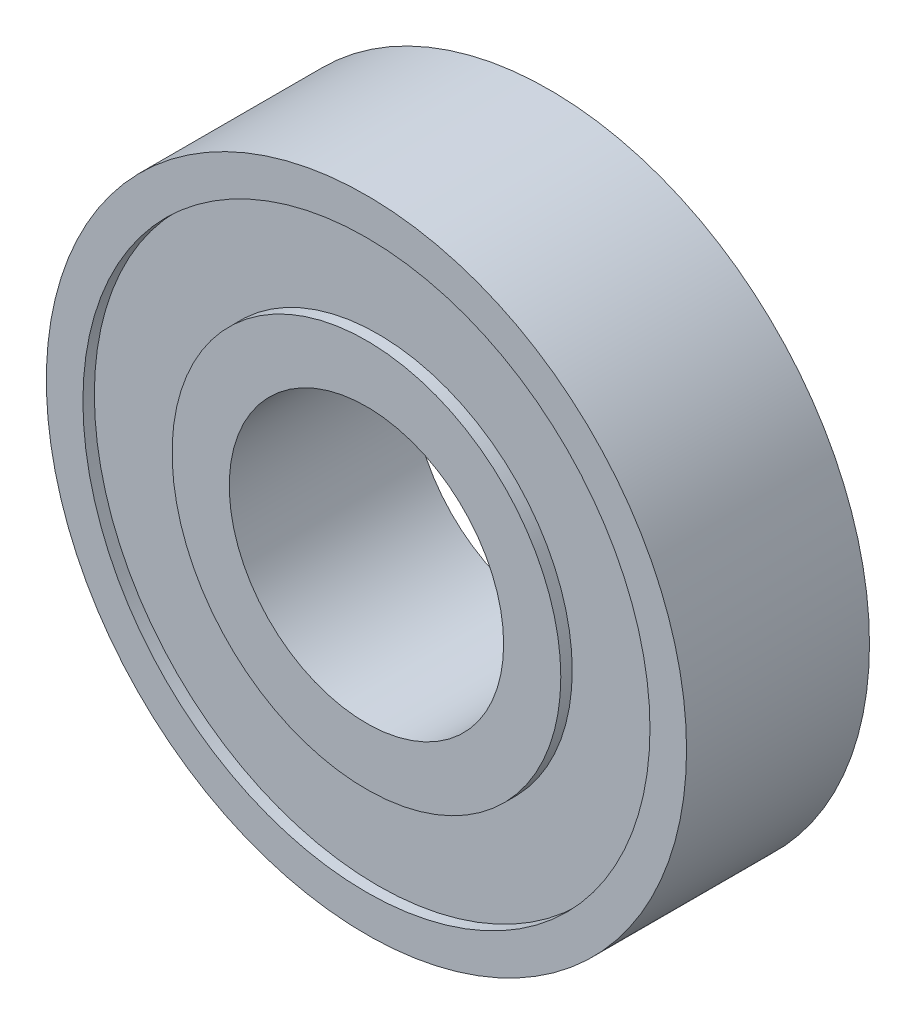
from build123d import *

# Parameters (mm, degrees)
SKETCH_1_R          = 14
EXTRUDE_1_DEPTH     = 4
SKETCH_2_R          = 6
CUT_EXTRUDE_1_DEPTH = 9
SKETCH_3_R          = 12.4
SKETCH_3_R_2        = 8.5
CUT_EXTRUDE_2_DEPTH = 0.5


with BuildPart() as part:
    # 草圖1 → 填料-伸長1 (new body, symmetric)
    with BuildSketch(Plane.XY):
        Circle(SKETCH_1_R)
    extrude(amount=EXTRUDE_1_DEPTH, both=True)

    # 草圖2 → 除料-伸長1 (cut, through all)
    with BuildSketch(Plane.XY.offset(4)):
        Circle(SKETCH_2_R)
    extrude(amount=-CUT_EXTRUDE_1_DEPTH, mode=Mode.SUBTRACT)

    # 草圖3 → 除料-伸長2 (cut)
    with BuildSketch(Plane.XY.offset(4)):
        Circle(SKETCH_3_R)
        Circle(SKETCH_3_R_2, mode=Mode.SUBTRACT)
    cut_extrude_2 = extrude(amount=-CUT_EXTRUDE_2_DEPTH, mode=Mode.SUBTRACT)

    # 鏡射1: 除料-伸長2 across plane
    add(cut_extrude_2.mirror(Plane.XY), mode=Mode.SUBTRACT)


solid = part.part
